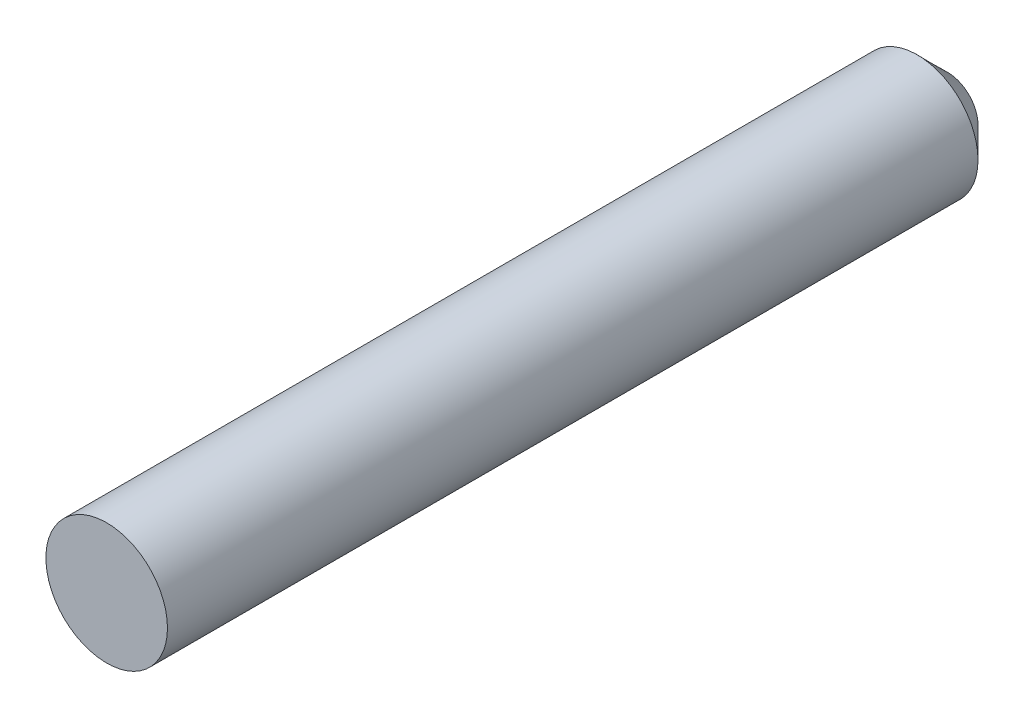
from build123d import *

# Parameters (mm, degrees)
SKETCH1_R           = 6
BOSS_EXTRUDE1_DEPTH = 83
CHAMFER1_SIZE       = 3


with BuildPart() as part:
    # Sketch1 → Boss-Extrude1 (new body)
    with BuildSketch(Plane.XY):
        Circle(SKETCH1_R)
    extrude(amount=BOSS_EXTRUDE1_DEPTH)

    # Chamfer1
    chamfer1_edges = [part.edges().sort_by_distance(p)[0] for p in [
        (-6, 0, 0),
    ]]
    chamfer(chamfer1_edges, length=CHAMFER1_SIZE)


solid = part.part
